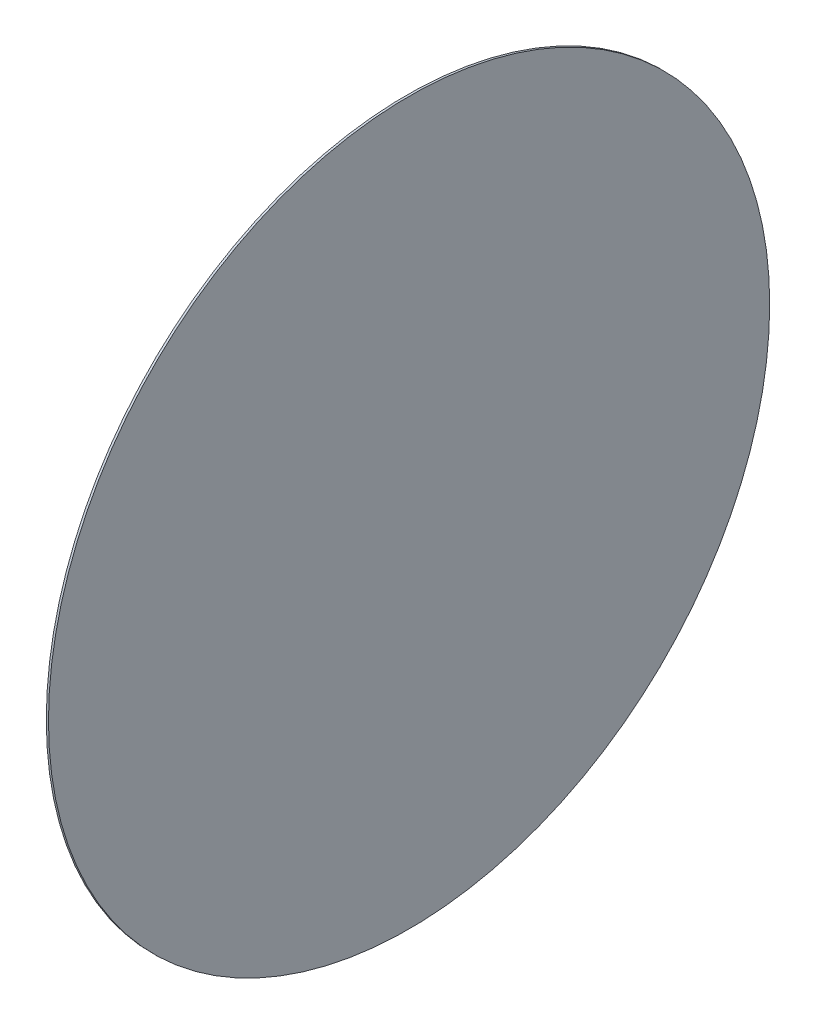
from build123d import *

# Parameters (mm, degrees)
SKETCH_1_W = 0.054
SKETCH_1_H = 9


with BuildPart() as part:
    # 草图1 → 旋转2 (revolve)
    with BuildSketch(Plane.XY, mode=Mode.PRIVATE) as revolve_2_sk:
        with Locations((0.027, 4.5)):
            Rectangle(SKETCH_1_W, SKETCH_1_H)
    revolve(revolve_2_sk.sketch.rotate(Axis((0, 0, 0), (1, 0, 0)), 90), axis=Axis((0, 0, 0), (1, 0, 0)))  # turned: the seam where the file's is


solid = part.part
